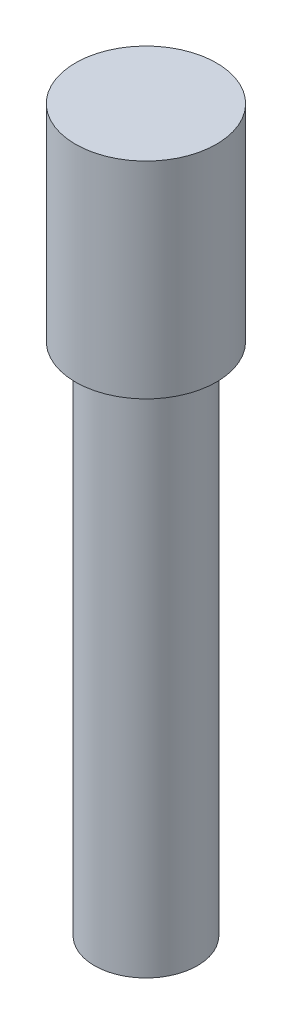
from build123d import *

# Parameters (mm, degrees)
SKETCH1_R           = 0.5
BOSS_EXTRUDE1_DEPTH = 5
SKETCH2_R           = 0.684508396
BOSS_EXTRUDE2_DEPTH = 2


with BuildPart() as part:
    # Sketch1 → Boss-Extrude1 (new body)
    with BuildSketch(Plane(origin=(0, 0, 0), x_dir=(1, 0, 0), z_dir=(0, 1, 0))):
        Circle(SKETCH1_R)
    extrude(amount=BOSS_EXTRUDE1_DEPTH)

    # Sketch2 → Boss-Extrude2 (add)
    with BuildSketch(Plane(origin=(0, 5, 0), x_dir=(1, 0, 0), z_dir=(0, 1, 0))):
        Circle(SKETCH2_R)
    extrude(amount=BOSS_EXTRUDE2_DEPTH)


solid = part.part
